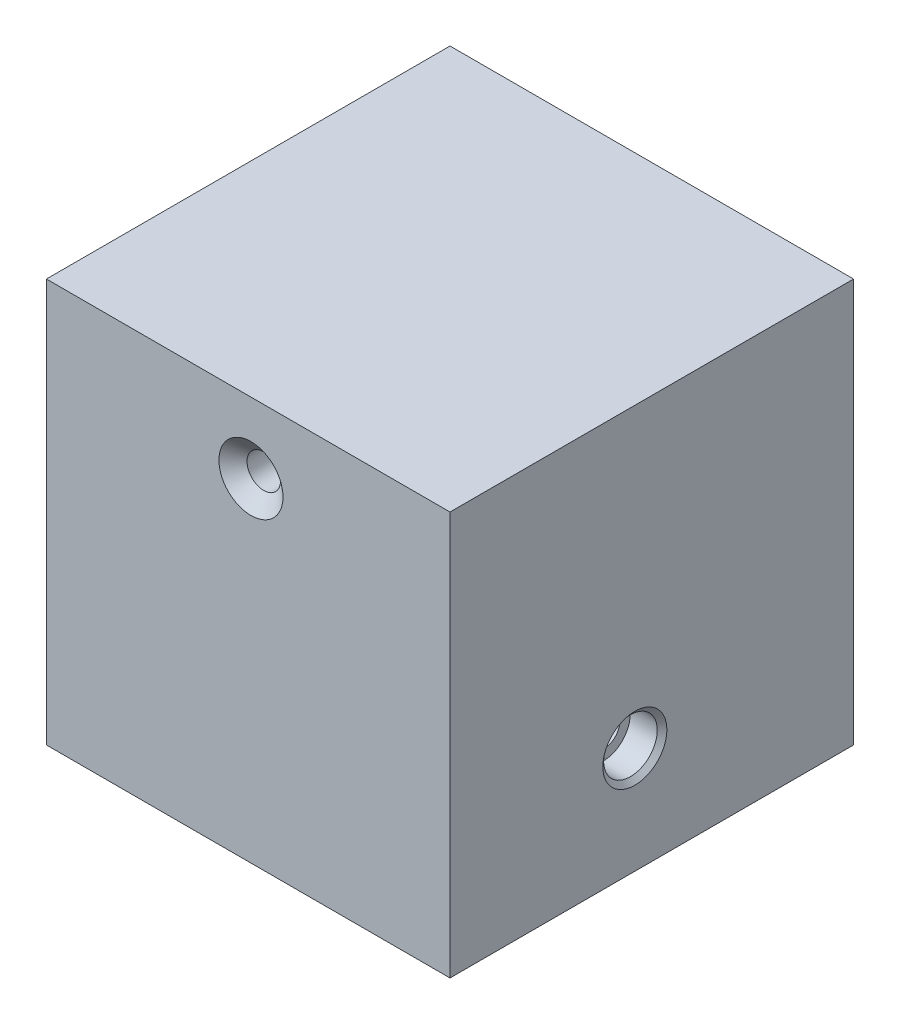
from build123d import *

# Parameters (mm, degrees)
SKETCH1_W           = 101.6
SKETCH1_H           = 101.6
BOSS_EXTRUDE1_DEPTH = 101.6
SKETCH6_R           = 6.922774564
CUT_EXTRUDE1_DEPTH  = 12.7
CHAMFER2_SIZE       = 2.54
SKETCH7_R           = 4.2164
BOSS_EXTRUDE2_DEPTH = 0.127


with BuildPart() as part:
    # Sketch1 → Boss-Extrude1 (new body)
    with BuildSketch(Plane.XY):
        with Locations((50.8, 50.8)):
            Rectangle(SKETCH1_W, SKETCH1_H)
    extrude(amount=BOSS_EXTRUDE1_DEPTH)

    # Sketch3 → CSK for 5/16 Flat Head Machine Screw (100)1 (revolve, cut)
    with BuildSketch(Plane(origin=(51.490087233, 83.841482184, 101.6), x_dir=(0, -1, 0), z_dir=(1, 0, 0))):
        Polygon((0, 0), (0, 101.6), (8.0645, 101.6), (4.2164, 98.371060709), (4.2164, 3.228939291), (8.0645, 0), align=None)
    revolve(axis=Axis((51.490087233, 83.841482184, 107.95), (0, 0, -1)), mode=Mode.SUBTRACT)

    # Sketch5 → CBORE for 5/16 Socket Head Cap Screw1 (revolve, cut)
    with BuildSketch(Plane(origin=(101.6, 26.823245181, 55.06253419), x_dir=(0, 0, -1), z_dir=(0, 1, 0))):
        Polygon((0, 0), (0, 101.6), (4.2164, 101.6), (4.2164, 7.9375), (6.74751, 7.9375), (6.74751, 1.105085823), (8.0645, 0), align=None)
    revolve(axis=Axis((107.95, 26.823245181, 55.06253419), (-1, 0, 0)), mode=Mode.SUBTRACT)

    # Sketch6 → Cut-Extrude1 (cut)
    with BuildSketch(Plane.ZY):
        with Locations((55.06253419, 26.823245181)):
            Circle(SKETCH6_R)
    extrude(amount=-CUT_EXTRUDE1_DEPTH, mode=Mode.SUBTRACT)

    # Chamfer2
    chamfer2_edges = [part.edges().sort_by_distance(p)[0] for p in [
        (0, 26.823245181, 48.139759626),
    ]]
    chamfer(chamfer2_edges, length=CHAMFER2_SIZE)

    # Sketch7 → Boss-Extrude2 (add, symmetric)
    with BuildSketch(Plane(origin=(50.8, 0, 0), x_dir=(0, 0, -1), z_dir=(1, 0, 0))):
        with Locations((-55.06253419, 26.823245181)):
            Circle(SKETCH7_R)
    extrude(amount=BOSS_EXTRUDE2_DEPTH, both=True)


solid = part.part
